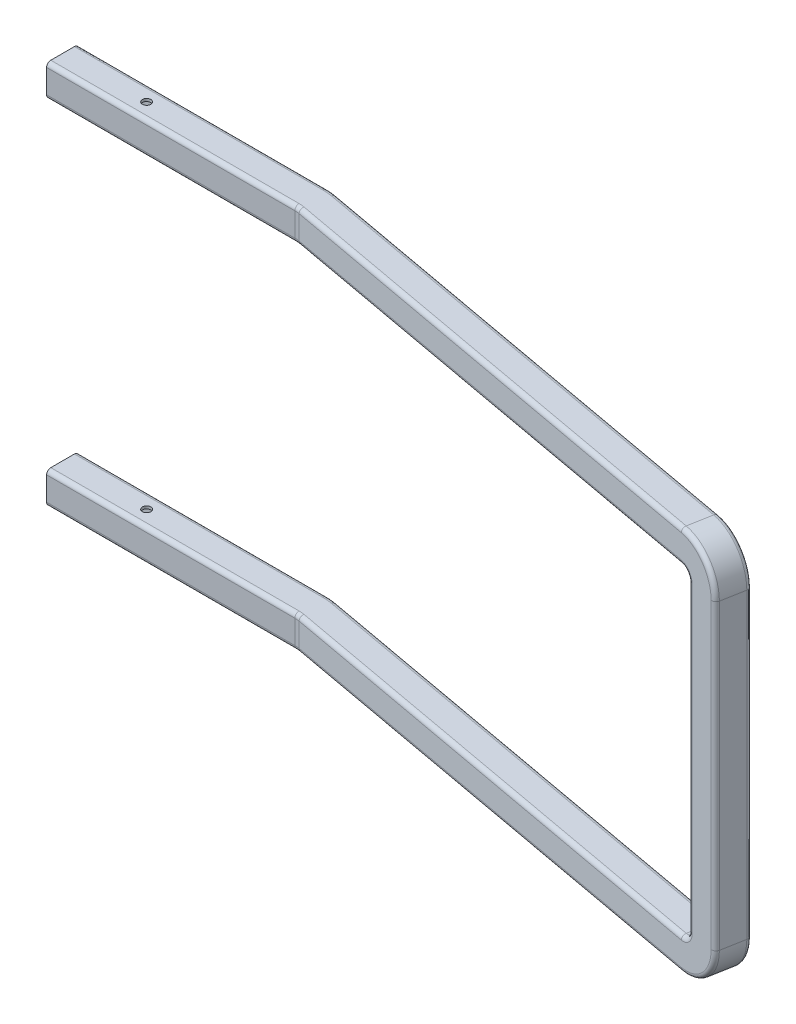
from build123d import *

# Parameters (mm, degrees)
CUT_EXTRUDE3_START = -211
SKETCH21_R         = 5
CUT_EXTRUDE3_DEPTH = 231.0500001


with BuildPart() as part:
    # Sweep-Thin3: sweep along a curve in space
    with BuildLine() as sweep_thin3_path:
        Line((0, 0, 0), (-50, 0, 0))
        Line((0, 0, 0), (245.484298454, 0, 0))
        ThreePointArc((254.442631788, 0, 0.809063194), (249.981695461, 0, 0.202676576), (245.484298454, 0, 0))
        Line((254.442631788, 0, 0.809063194), (810.776679593, 0, 102.125))
        ThreePointArc((840.291241677, -30, 107.5), (831.646626586, -8.786796564, 105.925698949), (810.776679593, 0, 102.125))
        Line((840.291241677, -30, 107.5), (840.291241677, -210, 107.5))
    # Sketch2 → Sweep-Thin3 (sweep)
    with BuildSketch(Plane(origin=(0, 0, 0), x_dir=(0, 0, -1), z_dir=(1, 0, 0))):
        with BuildLine():
            Line((14.05, 19.05), (-14.05, 19.05))
            ThreePointArc((-14.05, 19.05), (-17.585533906, 17.585533906), (-19.05, 14.05))
            Line((-19.05, 14.05), (-19.05, -14.05))
            ThreePointArc((-19.05, -14.05), (-17.585533906, -17.585533906), (-14.05, -19.05))
            Line((-14.05, -19.05), (14.05, -19.05))
            ThreePointArc((14.05, -19.05), (17.585533906, -17.585533906), (19.05, -14.05))
            Line((19.05, -14.05), (19.05, 14.05))
            ThreePointArc((19.05, 14.05), (17.585533906, 17.585533906), (14.05, 19.05))
        make_face()
        with BuildLine():
            Line((14.05, 15.875), (-14.05, 15.875))
            ThreePointArc((-14.05, 15.875), (-15.340469876, 15.340469876), (-15.875, 14.05))
            Line((-15.875, 14.05), (-15.875, -14.05))
            ThreePointArc((-15.875, -14.05), (-15.340469876, -15.340469876), (-14.05, -15.875))
            Line((-14.05, -15.875), (14.05, -15.875))
            ThreePointArc((14.05, -15.875), (15.340469876, -15.340469876), (15.875, -14.05))
            Line((15.875, -14.05), (15.875, 14.05))
            ThreePointArc((15.875, 14.05), (15.340469876, 15.340469876), (14.05, 15.875))
        make_face(mode=Mode.SUBTRACT)
    sweep_thin3 = sweep(path=sweep_thin3_path.line)

    # Sketch21 → Cut-Extrude3 (cut)
    with BuildSketch(Plane(origin=(0, 0, 0), x_dir=(1, 0, 0), z_dir=(0, 1, 0)).offset(CUT_EXTRUDE3_START)):
        with Locations((50, 0)):
            Circle(SKETCH21_R)
    cut_extrude3 = extrude(amount=CUT_EXTRUDE3_DEPTH, mode=Mode.SUBTRACT)

    # Mirror1: Sweep-Thin3, Cut-Extrude3 across plane
    add(sweep_thin3.mirror(Plane(origin=(0, -210, 0), x_dir=(0, 0, 1), z_dir=(0, -1, 0))))
    add(cut_extrude3.mirror(Plane(origin=(0, -210, 0), x_dir=(0, 0, 1), z_dir=(0, -1, 0))), mode=Mode.SUBTRACT)


solid = part.part
